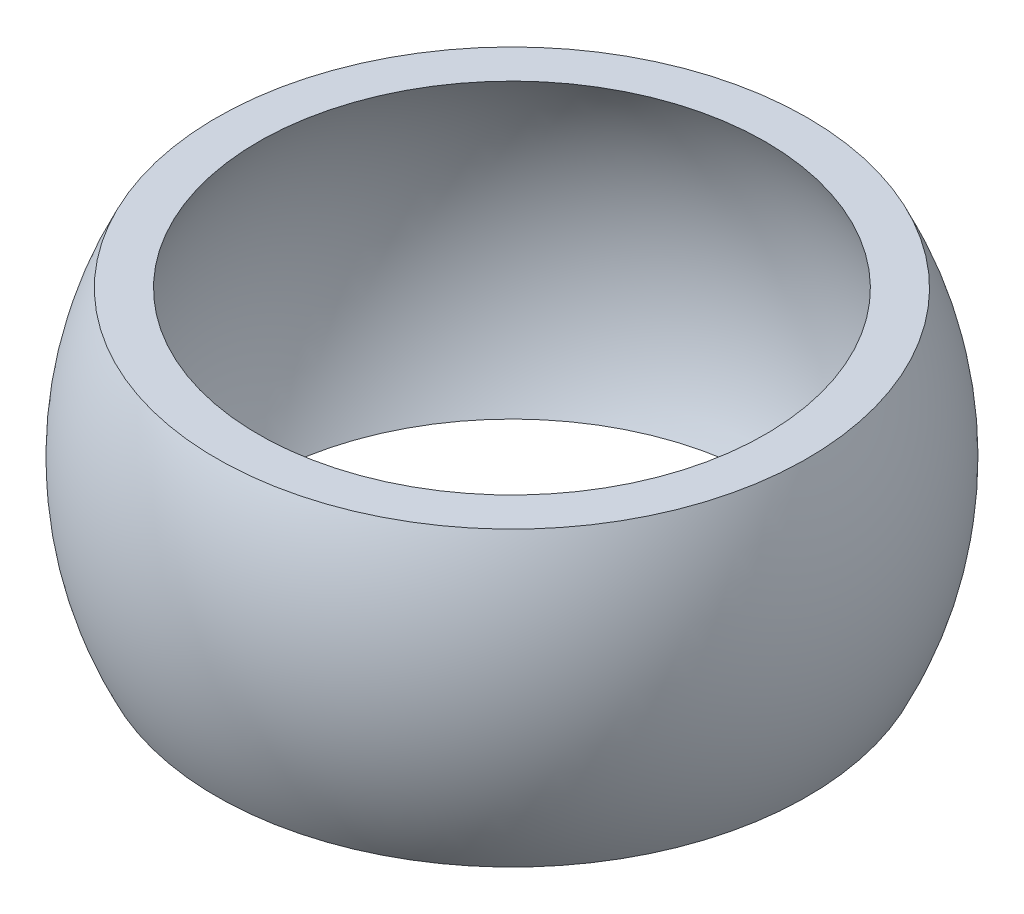
from build123d import *

# Parameters (mm, degrees)
SCALE1_SCALE = 0.25


with BuildPart() as part:
    # Sketch1 → Revolve1 (revolve)
    with BuildSketch(Plane.XY):
        with BuildLine():
            Line((12.124355653, 7), (14.124355653, 7))
            ThreePointArc((14.124355653, 7), (15.76380102, 0), (14.124355653, -7))
            Line((14.124355653, -7), (12.124355653, -7))
            ThreePointArc((12.124355653, -7), (13.522961568, -3.623466631), (14, 0))
            ThreePointArc((14, 0), (13.522961568, 3.623466631), (12.124355653, 7))
        make_face()
    revolve(axis=Axis((0, 0, 0), (0, 1, 0)))


with BuildPart() as part_1:
    # Scale1: scaled about (0, 0, 0)
    add(part.part.scale(SCALE1_SCALE))


solid = part_1.part
